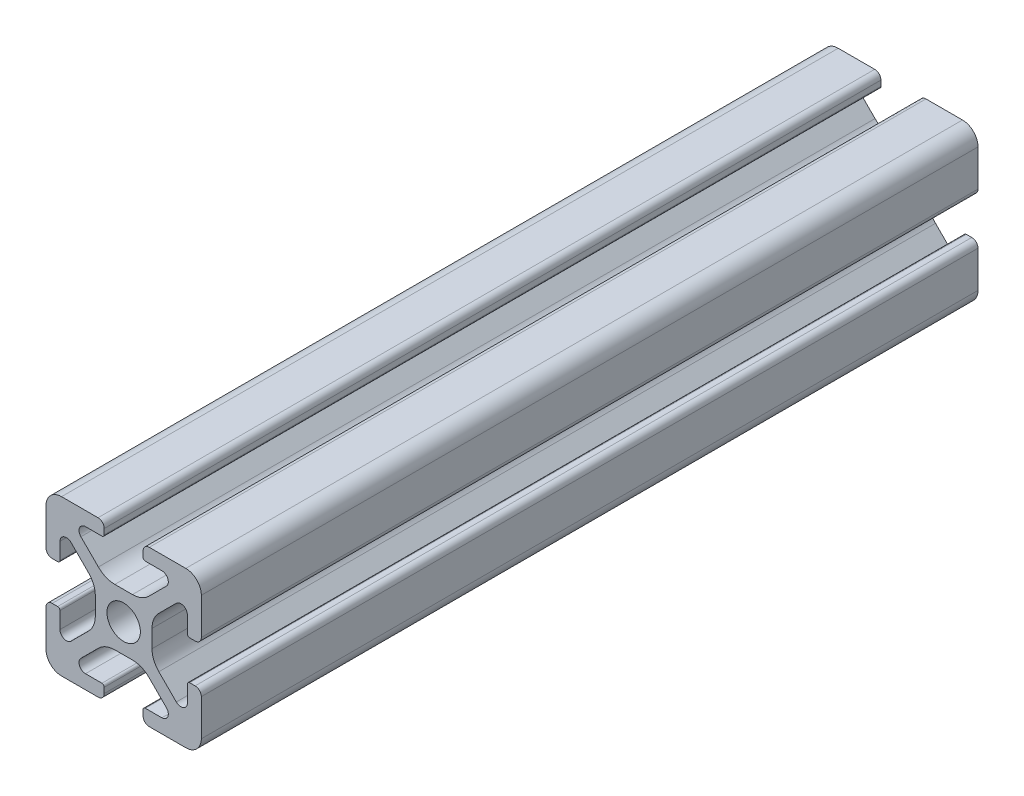
from build123d import *

# Parameters (mm, degrees)
SKETCH4_W              = 20
SKETCH4_H              = 20
BODY_DEPTH             = 100
SKETCH16_OUTSIDE_W     = 42.784
SKETCH16_OUTSIDE_H     = 42.784
SKETCH16_OUTSIDE_R     = 2.15
CUT_PROFILE_DEPTH      = 26
CUT_PROFILE_DEPTH_BACK = 76


with BuildPart() as part:
    # Sketch4 → Body (new body)
    with BuildSketch(Plane.XY.offset(25)):
        Rectangle(SKETCH4_W, SKETCH4_H)
    extrude(amount=-BODY_DEPTH)

    # Sketch16 outside → Cut-Profile (cut, two sides)
    with BuildSketch(Plane.XY) as cut_profile_sk:
        Rectangle(SKETCH16_OUTSIDE_W, SKETCH16_OUTSIDE_H)
        with BuildLine():
            Line((4.917588389, -8.199999991), (2.799999989, -8.199999991))
            ThreePointArc((2.799999989, -8.199999991), (2.587867955, -8.287867957), (2.499999989, -8.499999991))
            Line((2.499999989, -8.499999991), (2.499999989, -9.199999991))
            ThreePointArc((2.499999989, -9.199999991), (2.734314564, -9.765685416), (3.299999989, -9.999999991))
            Line((3.299999989, -9.999999991), (7.999999989, -9.999999991))
            ThreePointArc((7.999999989, -9.999999991), (9.414213552, -9.414213554), (9.999999989, -7.999999991))
            Line((9.999999989, -7.999999991), (9.999999989, -3.299999991))
            ThreePointArc((9.999999989, -3.299999991), (9.765685414, -2.734314566), (9.199999989, -2.499999991))
            Line((9.199999989, -2.499999991), (8.499999989, -2.499999991))
            ThreePointArc((8.499999989, -2.499999991), (8.287867955, -2.587867957), (8.199999989, -2.799999991))
            Line((8.199999989, -2.799999991), (8.199999989, -4.917588391))
            ThreePointArc((8.199999989, -4.917588391), (7.686138511, -5.686636441), (6.778984485, -5.506192286))
            Line((6.778984485, -5.506192286), (4.528679645, -3.255887446))
            ThreePointArc((4.528679645, -3.255887446), (3.878361392, -2.282617401), (3.64999999, -1.134567106))
            Line((3.64999999, -1.134567106), (3.64999999, 1.134567104))
            ThreePointArc((3.64999999, 1.134567104), (3.878361393, 2.282617402), (4.528679647, 3.255887448))
            Line((4.528679647, 3.255887448), (6.778984487, 5.506192288))
            ThreePointArc((6.778984487, 5.506192288), (7.686138506, 5.686636442), (8.199999981, 4.917588398))
            Line((8.199999981, 4.917588398), (8.199999981, 2.799999998))
            ThreePointArc((8.199999981, 2.799999998), (8.287867946, 2.587867964), (8.499999981, 2.499999998))
            Line((8.499999981, 2.499999998), (9.199999981, 2.499999998))
            ThreePointArc((9.199999981, 2.499999998), (9.765685406, 2.734314573), (9.999999981, 3.299999998))
            Line((9.999999981, 3.299999998), (9.999999981, 7.999999998))
            ThreePointArc((9.999999981, 7.999999998), (9.414213543, 9.41421356), (7.999999981, 9.999999998))
            Line((7.999999981, 9.999999998), (3.299999981, 9.999999998))
            ThreePointArc((3.299999981, 9.999999998), (2.734314556, 9.765685423), (2.499999981, 9.199999998))
            Line((2.499999981, 9.199999998), (2.499999981, 8.499999998))
            ThreePointArc((2.499999981, 8.499999998), (2.587867946, 8.287867964), (2.799999981, 8.199999998))
            Line((2.799999981, 8.199999998), (4.917588381, 8.199999998))
            ThreePointArc((4.917588381, 8.199999998), (5.68663643, 7.68613852), (5.506192275, 6.778984494))
            Line((5.506192275, 6.778984494), (3.255887435, 4.528679654))
            ThreePointArc((3.255887435, 4.528679654), (2.28261739, 3.878361401), (1.134567095, 3.649999999))
            Line((1.134567095, 3.649999999), (-1.134567115, 3.649999999))
            ThreePointArc((-1.134567115, 3.649999999), (-2.282617412, 3.878361401), (-3.255887459, 4.528679655))
            Line((-3.255887459, 4.528679655), (-5.506192299, 6.778984495))
            ThreePointArc((-5.506192299, 6.778984495), (-5.686636452, 7.686138515), (-4.917588409, 8.199999989))
            Line((-4.917588409, 8.199999989), (-2.800000009, 8.199999989))
            ThreePointArc((-2.800000009, 8.199999989), (-2.587867974, 8.287867955), (-2.500000009, 8.499999989))
            Line((-2.500000009, 8.499999989), (-2.500000009, 9.199999989))
            ThreePointArc((-2.500000009, 9.199999989), (-2.734314584, 9.765685414), (-3.300000009, 9.999999989))
            Line((-3.300000009, 9.999999989), (-8.000000009, 9.999999989))
            ThreePointArc((-8.000000009, 9.999999989), (-9.414213571, 9.414213552), (-10.000000009, 7.999999989))
            Line((-10.000000009, 7.999999989), (-10.000000009, 3.299999989))
            ThreePointArc((-10.000000009, 3.299999989), (-9.765685434, 2.734314564), (-9.200000009, 2.499999989))
            Line((-9.200000009, 2.499999989), (-8.500000009, 2.499999989))
            ThreePointArc((-8.500000009, 2.499999989), (-8.287867974, 2.587867955), (-8.200000009, 2.799999989))
            Line((-8.200000009, 2.799999989), (-8.200000009, 4.917588389))
            ThreePointArc((-8.200000009, 4.917588389), (-7.686138531, 5.686636438), (-6.778984504, 5.506192284))
            Line((-6.778984504, 5.506192284), (-4.528679664, 3.255887444))
            ThreePointArc((-4.528679664, 3.255887444), (-3.878361412, 2.282617399), (-3.650000009, 1.134567104))
            Line((-3.650000009, 1.134567104), (-3.650000009, -1.134567106))
            ThreePointArc((-3.650000009, -1.134567106), (-3.878361412, -2.282617404), (-4.528679666, -3.25588745))
            Line((-4.528679666, -3.25588745), (-6.778984506, -5.50619229))
            ThreePointArc((-6.778984506, -5.50619229), (-7.686138526, -5.686636444), (-8.2, -4.9175884))
            Line((-8.2, -4.9175884), (-8.2, -2.8))
            ThreePointArc((-8.2, -2.8), (-8.287867966, -2.587867966), (-8.5, -2.5))
            Line((-8.5, -2.5), (-9.2, -2.5))
            ThreePointArc((-9.2, -2.5), (-9.765685425, -2.734314575), (-10, -3.3))
            Line((-10, -3.3), (-10, -8))
            ThreePointArc((-10, -8), (-9.414213562, -9.414213562), (-8, -10))
            Line((-8, -10), (-3.3, -10))
            ThreePointArc((-3.3, -10), (-2.734314575, -9.765685425), (-2.5, -9.2))
            Line((-2.5, -9.2), (-2.5, -8.5))
            ThreePointArc((-2.5, -8.5), (-2.587867966, -8.287867966), (-2.8, -8.2))
            Line((-2.8, -8.2), (-4.9175884, -8.2))
            ThreePointArc((-4.9175884, -8.2), (-5.686636449, -7.686138522), (-5.506192294, -6.778984496))
            Line((-5.506192294, -6.778984496), (-3.255887454, -4.528679656))
            ThreePointArc((-3.255887454, -4.528679656), (-2.282617409, -3.878361403), (-1.134567114, -3.650000001))
            Line((-1.134567114, -3.650000001), (1.134567096, -3.650000001))
            ThreePointArc((1.134567096, -3.650000001), (2.282617393, -3.878361403), (3.255887439, -4.528679657))
            Line((3.255887439, -4.528679657), (5.506192279, -6.778984497))
            ThreePointArc((5.506192279, -6.778984497), (5.686636433, -7.686138517), (4.917588389, -8.199999991))
        make_face(mode=Mode.SUBTRACT)
        Circle(SKETCH16_OUTSIDE_R)
    extrude(amount=CUT_PROFILE_DEPTH, mode=Mode.SUBTRACT)
    extrude(cut_profile_sk.sketch, amount=-CUT_PROFILE_DEPTH_BACK, mode=Mode.SUBTRACT)


solid = part.part
